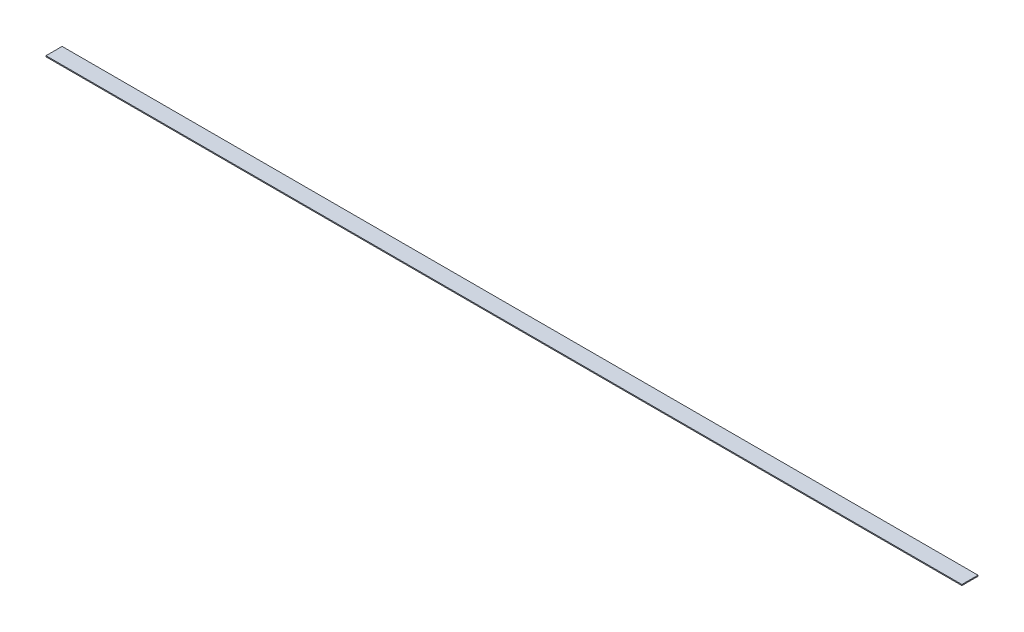
from build123d import *

# Parameters (mm, degrees)
SKETCH1_W           = 2889.25
SKETCH1_H           = 50.8
BOSS_EXTRUDE1_DEPTH = 3.175


with BuildPart() as part:
    # Sketch1 → Boss-Extrude1 (new body)
    with BuildSketch(Plane(origin=(0, 0, 0), x_dir=(1, 0, 0), z_dir=(0, 1, 0))):
        Rectangle(SKETCH1_W, SKETCH1_H)
    extrude(amount=BOSS_EXTRUDE1_DEPTH)


solid = part.part
